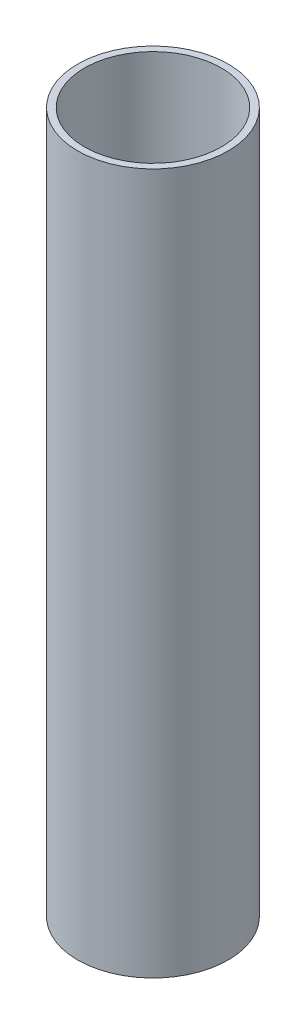
from build123d import *

# Parameters (mm, degrees)
SKETCH1_R           = 41.9
SKETCH1_R_2         = 38.1
BOSS_EXTRUDE1_DEPTH = 390


with BuildPart() as part:
    # Sketch1 → Boss-Extrude1 (new body)
    with BuildSketch(Plane(origin=(0, 0, 0), x_dir=(1, 0, 0), z_dir=(0, 1, 0))):
        Circle(SKETCH1_R)
        Circle(SKETCH1_R_2, mode=Mode.SUBTRACT)
    extrude(amount=BOSS_EXTRUDE1_DEPTH)


solid = part.part
